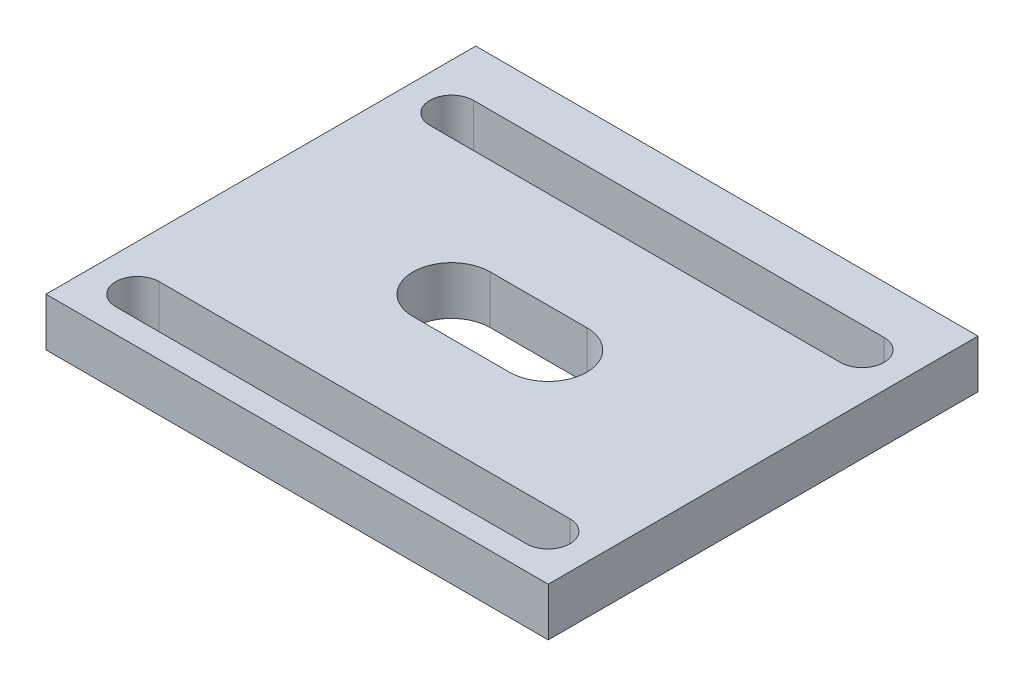
from build123d import *

# Parameters (mm, degrees)
SKETCH1_R           = 4
BOSS_EXTRUDE1_DEPTH = 5
CUT_EXTRUDE1_DEPTH  = 10
CUT_EXTRUDE2_DEPTH  = 10
CUT_EXTRUDE5_START  = -75
SKETCH5_R           = 1.6
CUT_EXTRUDE5_DEPTH  = 10
SKETCH6_W           = 85
SKETCH6_H           = 75
CUT_EXTRUDE6_DEPTH  = 10
SKETCH7_W           = 65
SKETCH7_H           = 15
CUT_EXTRUDE7_DEPTH  = 10
SKETCH8_W           = 12.986544032
SKETCH8_H           = 50
CUT_EXTRUDE8_DEPTH  = 10
SKETCH9_W           = 52.013455968
SKETCH9_H           = 5.5
CUT_EXTRUDE9_DEPTH  = 10


with BuildPart() as part:
    # Sketch1 → Boss-Extrude1 (new body)
    with BuildSketch(Plane(origin=(0, 0, 0), x_dir=(1, 0, 0), z_dir=(0, 1, 0))):
        with BuildLine():
            Line((-57.373232891, 17.353168425), (-57.373232891, -35.646831575))
            Line((-57.373232891, -35.646831575), (-57.373232891, -43.646831575))
            Line((-57.373232891, -43.646831575), (92.626767109, -43.646831575))
            Line((92.626767109, -43.646831575), (92.626767109, -35.646831575))
            Line((92.626767109, -35.646831575), (92.626767109, 29.353168425))
            ThreePointArc((92.626767109, 29.353168425), (92.040980672, 30.767381987), (90.626767109, 31.353168425))
            Line((90.626767109, 31.353168425), (26.626767109, 31.353168425))
            Line((26.626767109, 31.353168425), (-57.373232891, 31.353168425))
            Line((-57.373232891, 31.353168425), (-57.373232891, 17.353168425))
        make_face()
        with Locations((-25.373232891, -2.646831575)):
            Circle(SKETCH1_R, mode=Mode.SUBTRACT)
        with BuildLine():
            Line((32.363311142, 16.366624392), (74.890223077, 16.366624392))
            ThreePointArc((74.890223077, 16.366624392), (77.140223077, 14.116624392), (74.890223077, 11.866624392))
            Line((74.890223077, 11.866624392), (32.363311142, 11.866624392))
            ThreePointArc((32.363311142, 11.866624392), (30.113311142, 14.116624392), (32.363311142, 16.366624392))
        make_face(mode=Mode.SUBTRACT)
        with BuildLine():
            Line((32.363311142, -20.660287542), (74.890223077, -20.660287542))
            ThreePointArc((74.890223077, -20.660287542), (77.140223077, -18.410287542), (74.890223077, -16.160287542))
            Line((74.890223077, -16.160287542), (32.363311142, -16.160287542))
            ThreePointArc((32.363311142, -16.160287542), (30.113311142, -18.410287542), (32.363311142, -20.660287542))
        make_face(mode=Mode.SUBTRACT)
        with BuildLine():
            Line((48.626767109, 1.853168425), (58.626767109, 1.853168425))
            ThreePointArc((58.626767109, 1.853168425), (62.626767109, -2.146831575), (58.626767109, -6.146831575))
            Line((58.626767109, -6.146831575), (48.626767109, -6.146831575))
            ThreePointArc((48.626767109, -6.146831575), (44.626767109, -2.146831575), (48.626767109, 1.853168425))
        make_face(mode=Mode.SUBTRACT)
    extrude(amount=BOSS_EXTRUDE1_DEPTH)

    # Sketch2 → Cut-Extrude1 (cut)
    with BuildSketch(Plane(origin=(0, 5, 0), x_dir=(1, 0, 0), z_dir=(0, 1, 0))):
        with BuildLine():
            Line((-47.394048171, 11.623983705), (-13.35241761, 11.623983705))
            ThreePointArc((-13.35241761, 11.623983705), (-11.10241761, 9.373983705), (-13.35241761, 7.123983705))
            Line((-13.35241761, 7.123983705), (-47.394048171, 7.123983705))
            ThreePointArc((-47.394048171, 7.123983705), (-49.644048171, 9.373983705), (-47.394048171, 11.623983705))
        make_face()
        with BuildLine():
            Line((-47.394048171, -16.917646855), (-13.35241761, -16.917646855))
            ThreePointArc((-13.35241761, -16.917646855), (-11.10241761, -14.667646855), (-13.35241761, -12.417646855))
            Line((-13.35241761, -12.417646855), (-47.394048171, -12.417646855))
            ThreePointArc((-47.394048171, -12.417646855), (-49.644048171, -14.667646855), (-47.394048171, -16.917646855))
        make_face()
        with BuildLine():
            Line((-35.373232891, 1.353168425), (-25.373232891, 1.353168425))
            ThreePointArc((-25.373232891, 1.353168425), (-21.373232891, -2.646831575), (-25.373232891, -6.646831575))
            Line((-25.373232891, -6.646831575), (-35.373232891, -6.646831575))
            ThreePointArc((-35.373232891, -6.646831575), (-39.373232891, -2.646831575), (-35.373232891, 1.353168425))
        make_face()
    extrude(amount=-CUT_EXTRUDE1_DEPTH, mode=Mode.SUBTRACT)

    # Sketch3 → Cut-Extrude2 (cut)
    with BuildSketch(Plane(origin=(0, 5, 0), x_dir=(1, 0, 0), z_dir=(0, 1, 0))):
        with BuildLine():
            Line((21.749403979, 13.353168425), (21.749403979, 3.353168425))
            ThreePointArc((21.749403979, 3.353168425), (17.749403979, -0.646831575), (13.749403979, 3.353168425))
            Line((13.749403979, 3.353168425), (13.749403979, 13.353168425))
            ThreePointArc((13.749403979, 13.353168425), (17.749403979, 17.353168425), (21.749403979, 13.353168425))
        make_face()
        with BuildLine():
            Line((21.749403979, -14.646831575), (21.749403979, -24.646831575))
            ThreePointArc((21.749403979, -24.646831575), (17.749403979, -28.646831575), (13.749403979, -24.646831575))
            Line((13.749403979, -24.646831575), (13.749403979, -14.646831575))
            ThreePointArc((13.749403979, -14.646831575), (17.749403979, -10.646831575), (21.749403979, -14.646831575))
        make_face()
    extrude(amount=-CUT_EXTRUDE2_DEPTH, mode=Mode.SUBTRACT)

    # Sketch5 → Cut-Extrude5 (cut)
    with BuildSketch(Plane.XY.offset(43.646831575).offset(CUT_EXTRUDE5_START)):
        with Locations((-47.373232891, 2.5)):
            Circle(SKETCH5_R)
        with Locations((82.626767109, 2.5)):
            Circle(SKETCH5_R)
    extrude(amount=CUT_EXTRUDE5_DEPTH, mode=Mode.SUBTRACT)

    # Sketch6 → Cut-Extrude6 (cut)
    with BuildSketch(Plane(origin=(0, 5, 0), x_dir=(1, 0, 0), z_dir=(0, 1, 0))):
        with Locations((-14.873232891, -6.146831575)):
            Rectangle(SKETCH6_W, SKETCH6_H)
    extrude(amount=-CUT_EXTRUDE6_DEPTH, mode=Mode.SUBTRACT)

    # Sketch7 → Cut-Extrude7 (cut)
    with BuildSketch(Plane(origin=(0, 5, 0), x_dir=(1, 0, 0), z_dir=(0, 1, 0))):
        with Locations((60.126767109, -36.146831575)):
            Rectangle(SKETCH7_W, SKETCH7_H)
    extrude(amount=-CUT_EXTRUDE7_DEPTH, mode=Mode.SUBTRACT)

    # Sketch8 → Cut-Extrude8 (cut)
    with BuildSketch(Plane(origin=(0, 5, 0), x_dir=(1, 0, 0), z_dir=(0, 1, 0))):
        with BuildLine():
            Line((90.626767109, 31.353168425), (27.626767109, 31.353168425))
            Line((27.626767109, 31.353168425), (27.626767109, 21.353168425))
            Line((27.626767109, 21.353168425), (79.640223077, 21.353168425))
            Line((79.640223077, 21.353168425), (92.626767109, 21.353168425))
            Line((92.626767109, 21.353168425), (92.626767109, 29.353168425))
            ThreePointArc((92.626767109, 29.353168425), (92.040980672, 30.767381987), (90.626767109, 31.353168425))
        make_face()
        with Locations((86.133495093, -3.646831575)):
            Rectangle(SKETCH8_W, SKETCH8_H)
    extrude(amount=-CUT_EXTRUDE8_DEPTH, mode=Mode.SUBTRACT)

    # Sketch9 → Cut-Extrude9 (cut)
    with BuildSketch(Plane(origin=(0, 5, 0), x_dir=(1, 0, 0), z_dir=(0, 1, 0))):
        with Locations((53.633495093, -25.896831575)):
            Rectangle(SKETCH9_W, SKETCH9_H)
    extrude(amount=-CUT_EXTRUDE9_DEPTH, mode=Mode.SUBTRACT)


solid = part.part
